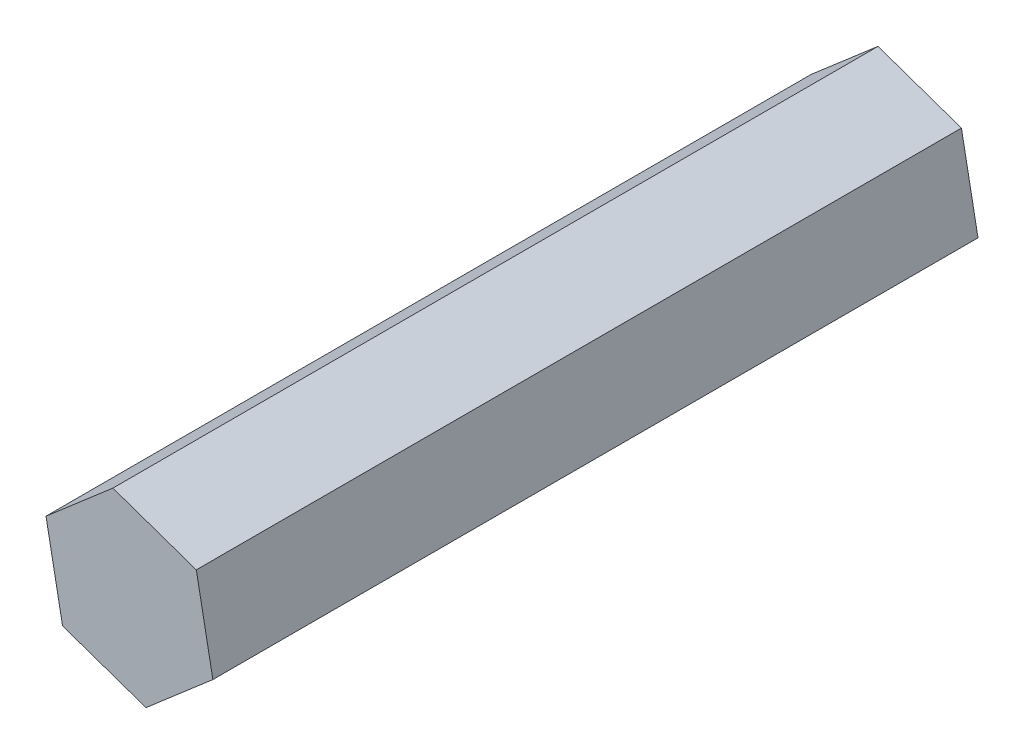
from build123d import *

# Parameters (mm, degrees)
BOSS_EXTRUDE1_DEPTH = 63.5


with BuildPart() as part:
    # Sketch1 → Boss-Extrude1 (new body)
    with BuildSketch(Plane.XY):
        Polygon((5.550187708, 4.791528956), (-1.374491945, 7.202368029), (-6.924679653, 2.410839073), (-5.550187708, -4.791528956), (1.374491945, -7.202368029), (6.924679653, -2.410839073), align=None)
    extrude(amount=BOSS_EXTRUDE1_DEPTH)


solid = part.part
